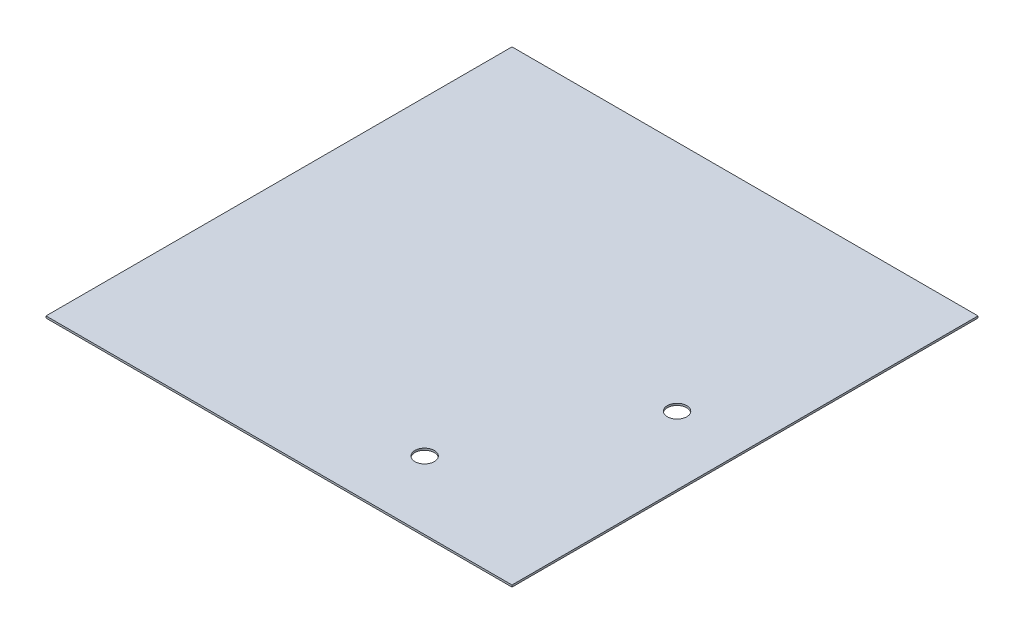
from build123d import *

# Parameters (mm, degrees)
SKETCH1_W           = 609.6
SKETCH1_H           = 609.6
BOSS_EXTRUDE1_DEPTH = 2.5
SKETCH2_R           = 12.7
CUT_EXTRUDE1_DEPTH  = 3.5


with BuildPart() as part:
    # Sketch1 → Boss-Extrude1 (new body)
    with BuildSketch(Plane(origin=(0, 0, 0), x_dir=(1, 0, 0), z_dir=(0, 1, 0))):
        Rectangle(SKETCH1_W, SKETCH1_H)
    extrude(amount=BOSS_EXTRUDE1_DEPTH)

    # Sketch2 → Cut-Extrude1 (cut, through all)
    with BuildSketch(Plane(origin=(0, 2.5, 0), x_dir=(1, 0, 0), z_dir=(0, 1, 0))):
        with Locations((101.6, -215.9)):
            Circle(SKETCH2_R)
        with Locations((215.9, 0)):
            Circle(SKETCH2_R)
    extrude(amount=-CUT_EXTRUDE1_DEPTH, mode=Mode.SUBTRACT)


solid = part.part
